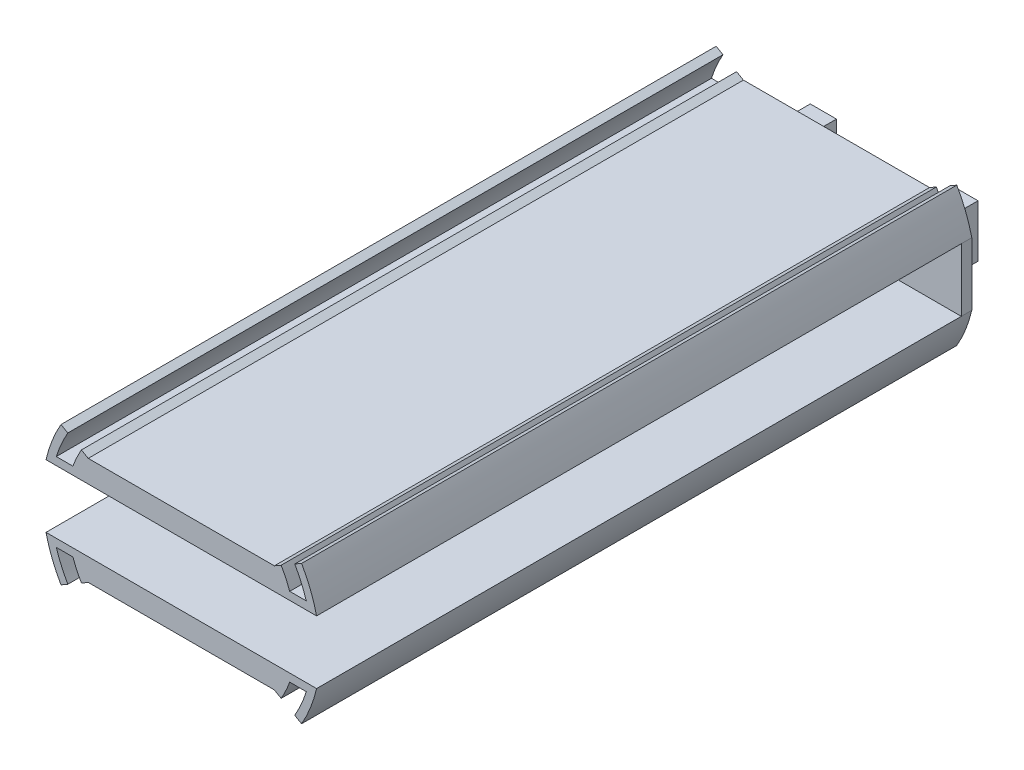
from build123d import *

# Parameters (mm, degrees)
BOSS_EXTRUDE2_DEPTH = 125
SKETCH2_W           = 51.623637996
SKETCH2_H           = 2
BOSS_EXTRUDE3_DEPTH = 12
SKETCH3_W           = 5
SKETCH3_H           = 10
BOSS_EXTRUDE4_DEPTH = 11
CUT_EXTRUDE1_REACH  = 16.942
SKETCH4_R           = 1.3


with BuildPart() as part:
    # Model → Boss-Extrude2 (new body)
    with BuildSketch(Plane.XY):
        with BuildLine():
            ThreePointArc((25.811818998, 6), (24.648760727, 9.730806474), (22.9496732, 13.25))
            Line((22.9496732, 13.25), (21.650635095, 12.5))
            ThreePointArc((21.650635095, 12.5), (22.886510643, 10.060200326), (23.848480035, 7.5))
            ThreePointArc((23.848480035, 7.5), (24.070588339, 6.753278984), (24.269322199, 6))
            Line((24.269322199, 6), (25.811818998, 6))
        make_face()
        with BuildLine():
            ThreePointArc((24.269322199, 6), (24.070588339, 6.753278984), (23.848480035, 7.5))
            Line((23.848480035, 7.5), (23.323807579, 7.5))
            Line((23.323807579, 7.5), (21.213203436, 7.5))
            Line((21.213203436, 7.5), (20.68211788, 7.5))
            ThreePointArc((20.68211788, 7.5), (20.937501331, 6.754334757), (21.166010489, 6))
            Line((21.166010489, 6), (24.269322199, 6))
        make_face()
        with BuildLine():
            Line((19.602295784, 6), (21.166010489, 6))
            ThreePointArc((21.166010489, 6), (20.937501331, 6.754334757), (20.68211788, 7.5))
            ThreePointArc((20.68211788, 7.5), (19.944263194, 9.285815292), (19.052558883, 11))
            Line((19.052558883, 11), (17.753520778, 10.25))
            ThreePointArc((17.753520778, 10.25), (18.798401069, 8.177415072), (19.602295784, 6))
        make_face()
        with BuildLine():
            Line((10.392304845, 6), (19.602295784, 6))
            ThreePointArc((19.602295784, 6), (18.798401069, 8.177415072), (17.753520778, 10.25))
            Line((17.753520778, 10.25), (10.392304845, 6))
        make_face()
        Polygon((17.753520778, 10.25), (-17.753520778, 10.25), (-10.392304845, 6), (10.392304845, 6), align=None)
        with BuildLine():
            Line((-17.753520778, 10.25), (-19.052558883, 11))
            ThreePointArc((-19.052558883, 11), (-19.944263194, 9.285815292), (-20.68211788, 7.5))
            ThreePointArc((-20.68211788, 7.5), (-20.937501331, 6.754334757), (-21.166010489, 6))
            Line((-21.166010489, 6), (-19.602295784, 6))
            ThreePointArc((-19.602295784, 6), (-18.798401069, 8.177415072), (-17.753520778, 10.25))
        make_face()
        with BuildLine():
            Line((-21.213203436, 7.5), (-23.323807579, 7.5))
            ThreePointArc((-23.323807579, 7.5), (-23.550822597, 6.753425426), (-23.75394704, 6))
            Line((-23.75394704, 6), (-21.685248442, 6))
            ThreePointArc((-21.685248442, 6), (-21.462334295, 6.754125156), (-21.213203436, 7.5))
        make_face()
        with BuildLine():
            Line((-23.323807579, 7.5), (-23.848480035, 7.5))
            ThreePointArc((-23.848480035, 7.5), (-24.070588339, 6.753278984), (-24.269322199, 6))
            Line((-24.269322199, 6), (-23.75394704, 6))
            ThreePointArc((-23.75394704, 6), (-23.550822597, 6.753425426), (-23.323807579, 7.5))
        make_face()
        with BuildLine():
            Line((-20.68211788, 7.5), (-21.213203436, 7.5))
            ThreePointArc((-21.213203436, 7.5), (-21.462334295, 6.754125156), (-21.685248442, 6))
            Line((-21.685248442, 6), (-21.166010489, 6))
            ThreePointArc((-21.166010489, 6), (-20.937501331, 6.754334757), (-20.68211788, 7.5))
        make_face()
        with BuildLine():
            Line((-21.650635095, 12.5), (-22.9496732, 13.25))
            ThreePointArc((-22.9496732, 13.25), (-24.648760727, 9.730806474), (-25.811818998, 6))
            Line((-25.811818998, 6), (-24.269322199, 6))
            ThreePointArc((-24.269322199, 6), (-24.070588339, 6.753278984), (-23.848480035, 7.5))
            ThreePointArc((-23.848480035, 7.5), (-22.886510643, 10.060200326), (-21.650635095, 12.5))
        make_face()
        with BuildLine():
            Line((-10.392304845, 6), (-17.753520778, 10.25))
            ThreePointArc((-17.753520778, 10.25), (-18.798401069, 8.177415072), (-19.602295784, 6))
            Line((-19.602295784, 6), (-10.392304845, 6))
        make_face()
        with BuildLine():
            Line((-24.269322199, -6), (-25.811818998, -6))
            ThreePointArc((-25.811818998, -6), (-24.648760727, -9.730806474), (-22.9496732, -13.25))
            Line((-22.9496732, -13.25), (-21.650635095, -12.5))
            ThreePointArc((-21.650635095, -12.5), (-22.886510643, -10.060200326), (-23.848480035, -7.5))
            ThreePointArc((-23.848480035, -7.5), (-24.070588339, -6.753278984), (-24.269322199, -6))
        make_face()
        with BuildLine():
            Line((-23.75394704, -6), (-24.269322199, -6))
            ThreePointArc((-24.269322199, -6), (-24.070588339, -6.753278984), (-23.848480035, -7.5))
            Line((-23.848480035, -7.5), (-23.323807579, -7.5))
            ThreePointArc((-23.323807579, -7.5), (-23.550822597, -6.753425426), (-23.75394704, -6))
        make_face()
        with BuildLine():
            Line((-21.685248442, -6), (-23.75394704, -6))
            ThreePointArc((-23.75394704, -6), (-23.550822597, -6.753425426), (-23.323807579, -7.5))
            Line((-23.323807579, -7.5), (-21.213203436, -7.5))
            ThreePointArc((-21.213203436, -7.5), (-21.462334295, -6.754125156), (-21.685248442, -6))
        make_face()
        with BuildLine():
            Line((-21.166010489, -6), (-21.685248442, -6))
            ThreePointArc((-21.685248442, -6), (-21.462334295, -6.754125156), (-21.213203436, -7.5))
            Line((-21.213203436, -7.5), (-20.68211788, -7.5))
            ThreePointArc((-20.68211788, -7.5), (-20.937501331, -6.754334757), (-21.166010489, -6))
        make_face()
        with BuildLine():
            Line((-19.602295784, -6), (-21.166010489, -6))
            ThreePointArc((-21.166010489, -6), (-20.937501331, -6.754334757), (-20.68211788, -7.5))
            ThreePointArc((-20.68211788, -7.5), (-19.944263194, -9.285815292), (-19.052558883, -11))
            Line((-19.052558883, -11), (-17.753520778, -10.25))
            ThreePointArc((-17.753520778, -10.25), (-18.798401069, -8.177415072), (-19.602295784, -6))
        make_face()
        with BuildLine():
            Line((-17.753520778, -10.25), (-10.392304845, -6))
            Line((-10.392304845, -6), (-19.602295784, -6))
            ThreePointArc((-19.602295784, -6), (-18.798401069, -8.177415072), (-17.753520778, -10.25))
        make_face()
        Polygon((17.753520778, -10.25), (10.392304845, -6), (-10.392304845, -6), (-17.753520778, -10.25), align=None)
        with BuildLine():
            ThreePointArc((17.753520778, -10.25), (18.798401069, -8.177415072), (19.602295784, -6))
            Line((19.602295784, -6), (10.392304845, -6))
            Line((10.392304845, -6), (17.753520778, -10.25))
        make_face()
        with BuildLine():
            ThreePointArc((20.68211788, -7.5), (20.937501331, -6.754334757), (21.166010489, -6))
            Line((21.166010489, -6), (19.602295784, -6))
            ThreePointArc((19.602295784, -6), (18.798401069, -8.177415072), (17.753520778, -10.25))
            Line((17.753520778, -10.25), (19.052558883, -11))
            ThreePointArc((19.052558883, -11), (19.944263194, -9.285815292), (20.68211788, -7.5))
        make_face()
        with BuildLine():
            ThreePointArc((23.848480035, -7.5), (24.070588339, -6.753278984), (24.269322199, -6))
            Line((24.269322199, -6), (21.166010489, -6))
            ThreePointArc((21.166010489, -6), (20.937501331, -6.754334757), (20.68211788, -7.5))
            Line((20.68211788, -7.5), (21.213203436, -7.5))
            Line((21.213203436, -7.5), (23.323807579, -7.5))
            Line((23.323807579, -7.5), (23.848480035, -7.5))
        make_face()
        with BuildLine():
            ThreePointArc((22.9496732, -13.25), (24.648760727, -9.730806474), (25.811818998, -6))
            Line((25.811818998, -6), (24.269322199, -6))
            ThreePointArc((24.269322199, -6), (24.070588339, -6.753278984), (23.848480035, -7.5))
            ThreePointArc((23.848480035, -7.5), (22.886510643, -10.060200326), (21.650635095, -12.5))
            Line((21.650635095, -12.5), (22.9496732, -13.25))
        make_face()
    extrude(amount=BOSS_EXTRUDE2_DEPTH)

    # Sketch2 → Boss-Extrude3 (add)
    with BuildSketch(Plane.XZ.offset(-6)):
        with Locations((0, 1)):
            Rectangle(SKETCH2_W, SKETCH2_H)
    extrude(amount=BOSS_EXTRUDE3_DEPTH)

    # Sketch3 → Boss-Extrude4 (add)
    with BuildSketch(Plane(origin=(0, 0, 0), x_dir=(-1, 0, 0), z_dir=(0, 0, -1))):
        with Locations((-13.5, -3.307781384)):
            Rectangle(SKETCH3_W, SKETCH3_H)
        with Locations((13.5, -3.307781384)):
            Rectangle(SKETCH3_W, SKETCH3_H)
    extrude(amount=BOSS_EXTRUDE4_DEPTH)

    # Sketch4 → Cut-Extrude1 (cut, up to next)
    with BuildSketch(Plane(origin=(0, 1.692218616, 0), x_dir=(1, 0, 0), z_dir=(0, 1, 0)), mode=Mode.PRIVATE) as cut_extrude1_sk1:
        with Locations((14, 5.5)):
            Circle(SKETCH4_R)
    cut_extrude1_tool1 = extrude(cut_extrude1_sk1.sketch, amount=-CUT_EXTRUDE1_REACH, mode=Mode.PRIVATE) & part.part
    add(cut_extrude1_tool1.solids().sort_by_distance((14, 1.692219, -5.5))[0], mode=Mode.SUBTRACT)
    # Sketch4 → Cut-Extrude1 (cut, up to next)
    with BuildSketch(Plane(origin=(0, 1.692218616, 0), x_dir=(1, 0, 0), z_dir=(0, 1, 0)), mode=Mode.PRIVATE) as cut_extrude1_sk2:
        with Locations((-14, 5.5)):
            Circle(SKETCH4_R)
    cut_extrude1_tool2 = extrude(cut_extrude1_sk2.sketch, amount=-CUT_EXTRUDE1_REACH, mode=Mode.PRIVATE) & part.part
    add(cut_extrude1_tool2.solids().sort_by_distance((-14, 1.692219, -5.5))[0], mode=Mode.SUBTRACT)


solid = part.part
